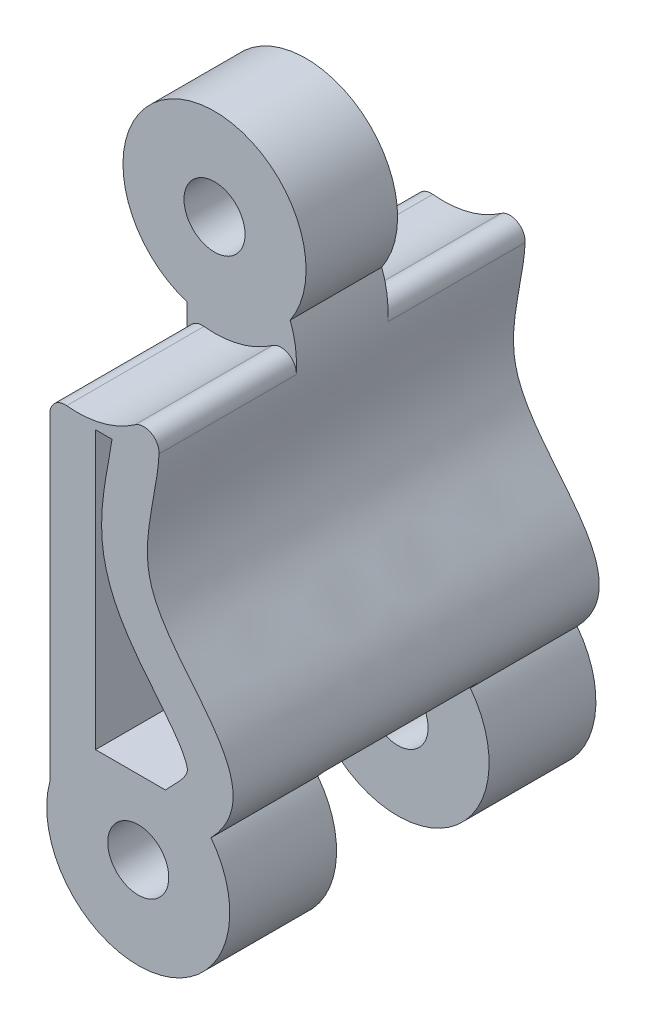
from build123d import *

# Parameters (mm, degrees)
SKETCH1_R               = 1
BOSS_EXTRUDE1_DEPTH     = 12
SKETCH2_R               = 3.3
CUT_EXTRUDE1_DEPTH      = 4.5
SKETCH3_R               = 3.3
CUT_EXTRUDE2_DEPTH      = 2.5
CUT_EXTRUDE2_DEPTH_BACK = 2.5
FILLET1_R               = 0.5


with BuildPart() as part:
    # Sketch1 → Boss-Extrude1 (new body)
    with BuildSketch(Plane.XY):
        with BuildLine():
            Line((-2.135466949, 39.096030813), (-2.135466949, 27.729845568))
            ThreePointArc((-2.135466949, 27.729845568), (1.347232905, 24.01546995), (3.148641663, 28.777896957))
            add(Edge.make_bspline(
                [(1.241090778, 40.266418218), (1.912265469, 38.58933293), (-0.897839085, 34.080207081), (5.393619541, 31.118616661), (3.148641663, 28.777896957)],
                knots=[0, 0, 0, 0, 0.42244107, 1, 1, 1, 1], degree=3))
            ThreePointArc((1.241090778, 40.266418218), (-2.218933753, 44.792695724), (-2.135466949, 39.096030813))
        make_face()
        with Locations((-1.236418473, 41.958147484)):
            Circle(SKETCH1_R, mode=Mode.SUBTRACT)
        with Locations((0.763581527, 26.958147484)):
            Circle(SKETCH1_R, mode=Mode.SUBTRACT)
        with BuildLine():
            Line((-0.096488374, 38.467254306), (-0.635466949, 38.467254306))
            Line((-0.635466949, 38.467254306), (-0.635466949, 29.386978342))
            Line((-0.635466949, 29.386978342), (1.654420667, 29.386978342))
            add(Edge.make_bspline(
                [(-0.096488374, 38.467254306), (-0.105436009, 38.401506099), (-0.136487964, 38.192292588), (-0.227961155, 37.671638495), (-0.385962112, 36.830023321), (-0.466607437, 35.853786297), (-0.377783184, 34.982876922), (-0.124189465, 34.070044509), (0.388397723, 33.151819221), (1.075806782, 32.251180688), (1.715646354, 31.483212968), (2.190959779, 30.839000473), (2.38372585, 30.391686489), (2.375574587, 30.305766013), (2.359962508, 30.224611722), (2.298151123, 30.09955086), (2.205002187, 29.972528912), (2.128350668, 29.882726381), (2.076053028, 29.826162431), (1.952733028, 29.698125272), (1.82945871, 29.569437868), (1.727842683, 29.463529821), (1.663452851, 29.396395722), (1.654420667, 29.386978342)],
                knots=[0.161996653, 0.161996653, 0.161996653, 0.161996653, 0.180586122, 0.21940152, 0.293759396, 0.368117272, 0.405296209, 0.442475147, 0.516833023, 0.591190898, 0.665548774, 0.73990665, 0.814264525, 0.888622401, 0.925801339, 0.962980277, 0.981569746, 0.99086448, 1.000159215, 1.009453949, 1.018748683, 1.032977813, 1.035301496, 1.035301496, 1.035301496, 1.035301496], degree=3))
        make_face(mode=Mode.SUBTRACT)
    extrude(amount=BOSS_EXTRUDE1_DEPTH)

    # Sketch2 → Cut-Extrude1 (cut)
    with BuildSketch(Plane.XY.offset(12)):
        with Locations((-1.236418473, 41.958147484)):
            Circle(SKETCH2_R)
    cut_extrude1 = extrude(amount=-CUT_EXTRUDE1_DEPTH, mode=Mode.SUBTRACT)

    # Mirror1: Cut-Extrude1 across plane
    add(cut_extrude1.mirror(Plane.XY.offset(6)), mode=Mode.SUBTRACT)

    # Sketch3 → Cut-Extrude2 (cut, two sides)
    with BuildSketch(Plane.XY.offset(6)) as cut_extrude2_sk:
        with Locations((0.763581527, 26.958147484)):
            Circle(SKETCH3_R)
    extrude(amount=CUT_EXTRUDE2_DEPTH, mode=Mode.SUBTRACT)
    extrude(cut_extrude2_sk.sketch, amount=-CUT_EXTRUDE2_DEPTH_BACK, mode=Mode.SUBTRACT)

    # Fillet1
    fillet1_edges = [part.edges().sort_by_distance(p)[0] for p in [
        (-2.135466949, 38.782976333, 9.75),
        (1.354946085, 39.914907476, 9.75),
        (-2.135466949, 38.782976333, 2.25),
        (1.354946085, 39.914907476, 2.25),
    ]]
    fillet(fillet1_edges, radius=FILLET1_R)


solid = part.part
